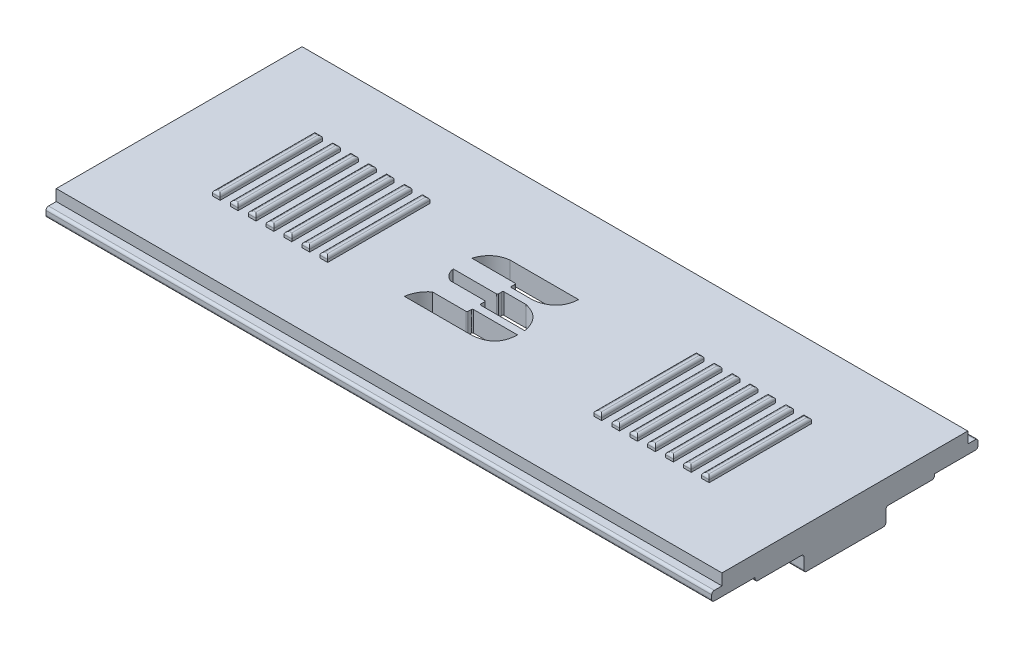
from build123d import *

# Parameters (mm, degrees)
SKETCH1_W           = 65
SKETCH1_H           = 28
BOSS_EXTRUDE1_DEPTH = 2
CUT_EXTRUDE4_DEPTH  = 10
FILLET1_R           = 1
SKETCH7_OUTSIDE_W   = 44.16
SKETCH7_OUTSIDE_H   = 18.16
CUT_EXTRUDE6_DEPTH  = 66.0000001
SKETCH10_W          = 4
SKETCH10_H          = 8
BOSS_EXTRUDE2_DEPTH = 2
FILLET2_R           = 0.25
FILLET3_R           = 0.25
SKETCH11_W          = 3.5
SKETCH11_H          = 17.5
BOSS_EXTRUDE3_DEPTH = 0.4
FILLET4_R           = 0.25
FILLET5_R           = 0.25
SKETCH9_W           = 0.75
SKETCH9_H           = 10
BOSS_EXTRUDE4_DEPTH = 0.5
FILLET9_R           = 0.25


with BuildPart() as part:
    # Sketch1 → Boss-Extrude1 (new body)
    with BuildSketch(Plane(origin=(0, 0, 0), x_dir=(1, 0, 0), z_dir=(0, 1, 0))):
        with Locations((-32.5, 14)):
            Rectangle(SKETCH1_W, SKETCH1_H)
    extrude(amount=BOSS_EXTRUDE1_DEPTH)

    # Sketch5 → Cut-Extrude4 (cut)
    with BuildSketch(Plane(origin=(0, 2, 0), x_dir=(1, 0, 0), z_dir=(0, 1, 0))):
        with BuildLine():
            Line((-30.110787357, 18.112760621), (-36.819982266, 18.112760621))
            add(Edge.make_bspline(
                [(-36.819982266, 18.112760621), (-38.342206509, 17.896158097), (-38.826861991, 16.40248141)],
                knots=[0, 0, 0, 1, 1, 1], degree=2))
            Line((-38.826861991, 16.40248141), (-34.616601015, 16.40248141))
            add(Edge.make_bspline(
                [(-34.616601015, 16.40248141), (-34.520325537, 16.407800186), (-34.513156135, 16.327358758)],
                knots=[0, 0, 0, 1, 1, 1], degree=2))
            Line((-34.513156135, 16.327358758), (-34.513156135, 15.955075648))
            add(Edge.make_bspline(
                [(-34.513156135, 15.955075648), (-34.513153253, 15.868534927), (-34.428521748, 15.845301142)],
                knots=[0, 0, 0, 1, 1, 1], degree=2))
            Line((-34.428521748, 15.845301142), (-32.229280366, 15.845301142))
            add(Edge.make_bspline(
                [(-30.110787357, 18.112760621), (-30.226644189, 16.176636702), (-32.229280366, 15.845301142)],
                knots=[0, 0, 0, 1, 1, 1], degree=2))
        make_face()
        with BuildLine():
            Line((-34.418606098, 15.133305986), (-32.279133751, 15.133305986))
            add(Edge.make_bspline(
                [(-32.279133751, 15.133305986), (-30.443960962, 14.735417604), (-30.110787357, 12.858969018)],
                knots=[0, 0, 0, 1, 1, 1], degree=2))
            Line((-30.110787357, 12.858969018), (-34.413134025, 12.858969018))
            add(Edge.make_bspline(
                [(-34.513156135, 12.977594451), (-34.500568581, 12.883603227), (-34.413134025, 12.858969018)],
                knots=[0, 0, 0, 1, 1, 1], degree=2))
            Line((-34.513156135, 12.977594451), (-34.513156135, 13.364418179))
            add(Edge.make_bspline(
                [(-34.616601015, 13.444585864), (-34.519850815, 13.453192342), (-34.513156135, 13.364418179)],
                knots=[0, 0, 0, 1, 1, 1], degree=2))
            Line((-34.616601015, 13.444585864), (-37.957172754, 13.444585864))
            add(Edge.make_bspline(
                [(-38.826861991, 14.587408915), (-38.701770756, 13.784616355), (-37.957172754, 13.444585864)],
                knots=[0, 0, 0, 1, 1, 1], degree=2))
            Line((-38.826861991, 14.587408915), (-34.616601015, 14.587408915))
            add(Edge.make_bspline(
                [(-34.513156135, 14.672896598), (-34.528042521, 14.588541692), (-34.616601015, 14.587408915)],
                knots=[0, 0, 0, 1, 1, 1], degree=2))
            Line((-34.513156135, 14.672896598), (-34.513156135, 15.012121394))
            add(Edge.make_bspline(
                [(-34.418606098, 15.133305986), (-34.509681283, 15.109834514), (-34.513156135, 15.012121394)],
                knots=[0, 0, 0, 1, 1, 1], degree=2))
        make_face()
        with BuildLine():
            Line((-30.110787357, 12.145471985), (-34.413134025, 12.145471985))
            add(Edge.make_bspline(
                [(-34.413134025, 12.145471985), (-34.501946395, 12.13028996), (-34.513156135, 12.035715311)],
                knots=[0, 0, 0, 1, 1, 1], degree=2))
            Line((-34.513156135, 12.035715311), (-34.513156135, 11.725008331))
            add(Edge.make_bspline(
                [(-34.616601015, 11.626977787), (-34.505638638, 11.615073322), (-34.513156135, 11.725008331)],
                knots=[0, 0, 0, 1, 1, 1], degree=2))
            Line((-34.616601015, 11.626977787), (-37.906213797, 11.626977787))
            add(Edge.make_bspline(
                [(-37.906213797, 11.626977787), (-38.73787267, 10.947958648), (-38.892405249, 9.883347444)],
                knots=[0, 0, 0, 1, 1, 1], degree=2))
            Line((-38.892405249, 9.883347444), (-32.210154892, 9.883347444))
            add(Edge.make_bspline(
                [(-30.110787357, 12.145471985), (-30.135485962, 10.117215922), (-32.210154892, 9.883347444)],
                knots=[0, 0, 0, 1, 1, 1], degree=2))
        make_face()
    extrude(amount=-CUT_EXTRUDE4_DEPTH, mode=Mode.SUBTRACT)

    # Fillet1
    fillet1_edges = [part.edges().sort_by_distance(p)[0] for p in [
        (0, 1, 0),
        (-65, 1, 0),
        (-65, 1, -28),
        (0, 1, -28),
    ]]
    fillet(fillet1_edges, radius=FILLET1_R)

    # Sketch7 outside → Cut-Extrude6 (cut, through all)
    with BuildSketch(Plane(origin=(0, 0, 0), x_dir=(0, 0, -1), z_dir=(1, 0, 0))):
        with Locations((14, 1)):
            Rectangle(SKETCH7_OUTSIDE_W, SKETCH7_OUTSIDE_H)
        Polygon((26, 2), (26, 0.9), (27, 0.9), (27, 0), (1, 0), (1, 0.9), (2, 0.9), (2, 2), align=None, mode=Mode.SUBTRACT)
    extrude(amount=-CUT_EXTRUDE6_DEPTH, mode=Mode.SUBTRACT)

    # Sketch10 → Boss-Extrude2 (add)
    with BuildSketch(Plane.XZ):
        with Locations((-2, -14)):
            Rectangle(SKETCH10_W, SKETCH10_H)
    extrude(amount=BOSS_EXTRUDE2_DEPTH)

    # Fillet2
    fillet2_edges = [part.edges().sort_by_distance(p)[0] for p in [
        (-2, 0, -10),
        (-4, 0, -14),
        (-2, 0, -18),
        (-2, -2, -10),
        (-4, -2, -14),
        (-2, -2, -18),
    ]]
    fillet(fillet2_edges, radius=FILLET2_R)

    # Fillet3
    fillet3_edges = [part.edges().sort_by_distance(p)[0] for p in [
        (-32.5, 0, -1),
        (-32.5, 0.9, -27),
        (-32.5, 0, -27),
        (-32.5, 0.9, -1),
    ]]
    fillet(fillet3_edges, radius=FILLET3_R)

    # Sketch11 → Boss-Extrude3 (add)
    with BuildSketch(Plane.XZ):
        with Locations((-1.75, -14)):
            Rectangle(SKETCH11_W, SKETCH11_H)
    extrude(amount=BOSS_EXTRUDE3_DEPTH)

    # Fillet4
    fillet4_edges = [part.edges().sort_by_distance(p)[0] for p in [
        (-1.75, -0.4, -5.25),
        (-1.75, -0.4, -22.75),
    ]]
    fillet(fillet4_edges, radius=FILLET4_R)

    # Fillet5
    fillet5_edges = [part.edges().sort_by_distance(p)[0] for p in [
        (-1.75, -0.4, -18),
        (-1.75, -0.4, -10),
    ]]
    fillet(fillet5_edges, radius=FILLET5_R)

    # Sketch9 → Boss-Extrude4 (add)
    with BuildSketch(Plane(origin=(0, 2, 0), x_dir=(1, 0, 0), z_dir=(0, 1, 0))):
        with Locations((-54.625, 14)):
            Rectangle(SKETCH9_W, SKETCH9_H)
        with Locations((-52.875, 14)):
            Rectangle(SKETCH9_W, SKETCH9_H)
        with Locations((-51.125, 14)):
            Rectangle(SKETCH9_W, SKETCH9_H)
        with Locations((-49.375, 14)):
            Rectangle(SKETCH9_W, SKETCH9_H)
        with Locations((-47.625, 14)):
            Rectangle(SKETCH9_W, SKETCH9_H)
        with Locations((-19.125, 14)):
            Rectangle(SKETCH9_W, SKETCH9_H)
        with Locations((-56.375, 14)):
            Rectangle(SKETCH9_W, SKETCH9_H)
        with Locations((-45.875, 14)):
            Rectangle(SKETCH9_W, SKETCH9_H)
        with Locations((-8.625, 14)):
            Rectangle(SKETCH9_W, SKETCH9_H)
        with Locations((-17.375, 14)):
            Rectangle(SKETCH9_W, SKETCH9_H)
        with Locations((-15.625, 14)):
            Rectangle(SKETCH9_W, SKETCH9_H)
        with Locations((-13.875, 14)):
            Rectangle(SKETCH9_W, SKETCH9_H)
        with Locations((-12.125, 14)):
            Rectangle(SKETCH9_W, SKETCH9_H)
        with Locations((-10.375, 14)):
            Rectangle(SKETCH9_W, SKETCH9_H)
    extrude(amount=BOSS_EXTRUDE4_DEPTH)

    # Fillet9
    fillet9_edges = [part.edges().sort_by_distance(p)[0] for p in [
        (-55, 2.5, -14),
        (-54.625, 2.5, -9),
        (-54.25, 2.5, -14),
        (-54.625, 2.5, -19),
        (-53.25, 2.5, -14),
        (-52.875, 2.5, -9),
        (-52.5, 2.5, -14),
        (-52.875, 2.5, -19),
        (-51.5, 2.5, -14),
        (-51.125, 2.5, -9),
        (-50.75, 2.5, -14),
        (-51.125, 2.5, -19),
        (-49.75, 2.5, -14),
        (-49.375, 2.5, -9),
        (-49, 2.5, -14),
        (-49.375, 2.5, -19),
        (-48, 2.5, -14),
        (-47.625, 2.5, -9),
        (-47.25, 2.5, -14),
        (-47.625, 2.5, -19),
        (-19.125, 2.5, -19),
        (-19.5, 2.5, -14),
        (-19.125, 2.5, -9),
        (-18.75, 2.5, -14),
        (-8.625, 2.5, -19),
        (-9, 2.5, -14),
        (-8.625, 2.5, -9),
        (-8.25, 2.5, -14),
        (-17.375, 2.5, -19),
        (-17.75, 2.5, -14),
        (-17.375, 2.5, -9),
        (-17, 2.5, -14),
        (-15.625, 2.5, -9),
        (-15.25, 2.5, -14),
        (-15.625, 2.5, -19),
        (-16, 2.5, -14),
        (-13.875, 2.5, -9),
        (-13.5, 2.5, -14),
        (-13.875, 2.5, -19),
        (-14.25, 2.5, -14),
        (-56, 2.5, -14),
        (-56.375, 2.5, -19),
        (-56.75, 2.5, -14),
        (-56.375, 2.5, -9),
        (-46.25, 2.5, -14),
        (-45.875, 2.5, -9),
        (-45.5, 2.5, -14),
        (-45.875, 2.5, -19),
        (-12.125, 2.5, -9),
        (-11.75, 2.5, -14),
        (-12.125, 2.5, -19),
        (-12.5, 2.5, -14),
        (-10.375, 2.5, -19),
        (-10.75, 2.5, -14),
        (-10.375, 2.5, -9),
        (-10, 2.5, -14),
    ]]
    fillet(fillet9_edges, radius=FILLET9_R)


solid = part.part
